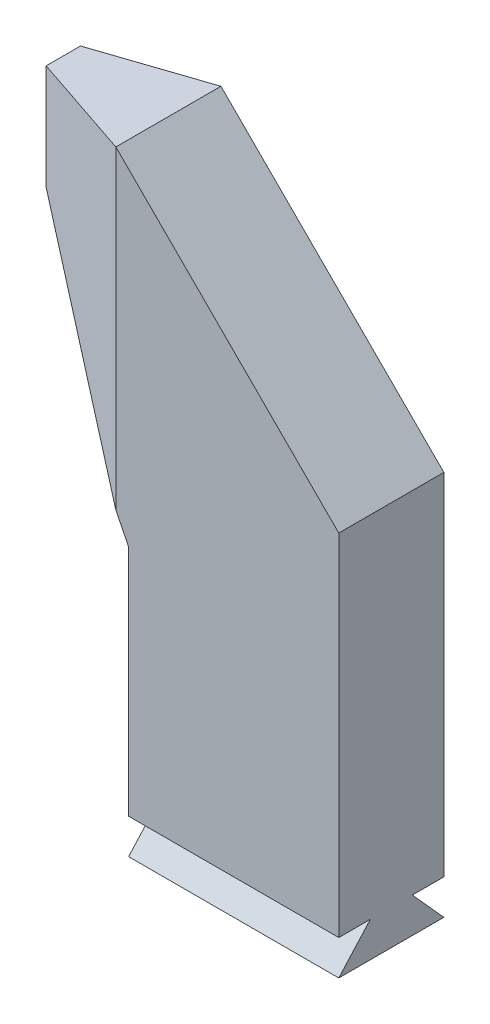
from build123d import *

# Parameters (mm, degrees)
BOSS_EXTRUDE1_DEPTH = 15
BOSS_EXTRUDE2_DEPTH = 60
CUT_EXTRUDE1_DEPTH  = 174.639610307
SCALE1_SCALE        = 0.3


with BuildPart() as part:
    # Sketch1 → Boss-Extrude1 (new body, symmetric)
    with BuildSketch(Plane.XY):
        Polygon((30, 0), (30, 100), (-33.639610307, 163.639610307), (-63.639610307, 163.639610307), (-63.639610307, 133.639610307), (-30, 66.606956932), (-30, 0), align=None)
    extrude(amount=BOSS_EXTRUDE1_DEPTH, both=True)

    # Sketch2 → Boss-Extrude2 (add)
    with BuildSketch(Plane(origin=(30, 0, 0), x_dir=(0, 0, -1), z_dir=(1, 0, 0))):
        Polygon((-15, -10), (15, -10), (6, 0), (-6, 0), align=None)
    extrude(amount=-BOSS_EXTRUDE2_DEPTH)

    # Sketch3 → Cut-Extrude1 (cut, through all)
    with BuildSketch(Plane(origin=(0, 163.639610307, 0), x_dir=(1, 0, 0), z_dir=(0, 1, 0))):
        Polygon((-63.639610307, 4.904583897), (-33.639610307, 15), (-33.639610307, 32.919088084), (-75.208668343, 32.919088084), (-75.208668343, 4.904583897), align=None)
        Polygon((-75.208668343, -32.919088084), (-75.208668343, -4.904583897), (-63.639610307, -4.904583897), (-33.639610307, -15), (-33.639610307, -32.919088084), align=None)
    extrude(amount=-CUT_EXTRUDE1_DEPTH, mode=Mode.SUBTRACT)


with BuildPart() as part_1:
    # Scale1: scaled about (-8.681688246, 73.036435377, 0)
    add(part.part.scale(SCALE1_SCALE).moved(Location((-6.077181772, 51.125504764, 0))))


solid = part_1.part
